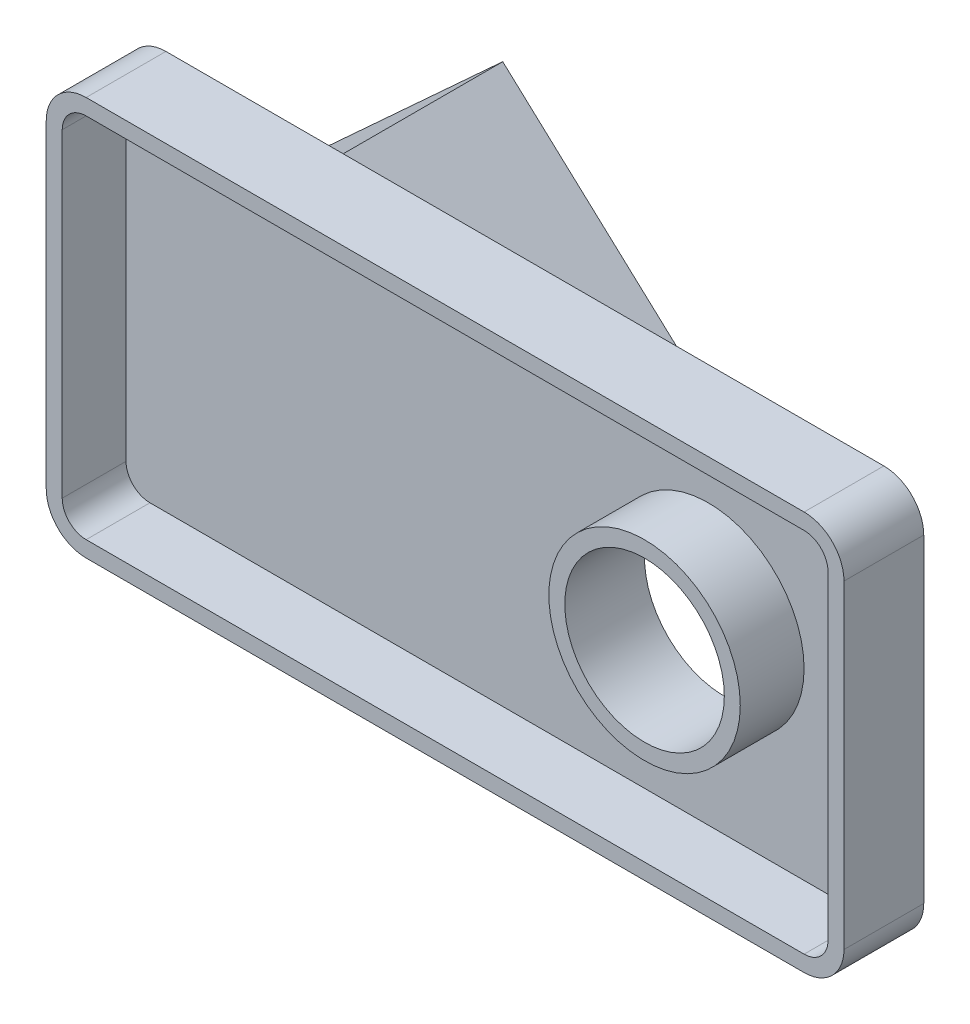
from build123d import *

# Parameters (mm, degrees)
SKICA1_W                = 200
SKICA1_H                = 100
SKICA1_R                = 20
P_IDAT_VYSUNUT_M1_DEPTH = 20
ZAOBLIT1_R              = 10
SKO_EPINA1_T            = -4
P_IDAT_VYSUNUT_M2_DEPTH = 40


with BuildPart() as part:
    # Skica1 → Přidat vysunutím1 (new body)
    with BuildSketch(Plane.XY):
        Rectangle(SKICA1_W, SKICA1_H)
        with Locations((50, 0)):
            Circle(SKICA1_R, mode=Mode.SUBTRACT)
    extrude(amount=P_IDAT_VYSUNUT_M1_DEPTH)

    # Zaoblit1
    zaoblit1_edges = [part.edges().sort_by_distance(p)[0] for p in [
        (-100, 50, 10),
        (100, 50, 10),
        (100, -50, 10),
        (-100, -50, 10),
    ]]
    fillet(zaoblit1_edges, radius=ZAOBLIT1_R)

    # Skořepina1
    sko_epina1_openings = [part.faces().sort_by_distance(p)[0] for p in [
        (0, 0, 20),
    ]]
    offset(amount=SKO_EPINA1_T, openings=sko_epina1_openings, kind=Kind.INTERSECTION)

    # Skica2 → Přidat vysunutím2 (add)
    with BuildSketch(Plane(origin=(0, 0, 0), x_dir=(-1, 0, 0), z_dir=(0, 0, -1))):
        Polygon((45.55, -50), (100, 0), (45.55, 50), (-8.9, 0), align=None)
    extrude(amount=P_IDAT_VYSUNUT_M2_DEPTH)


solid = part.part
